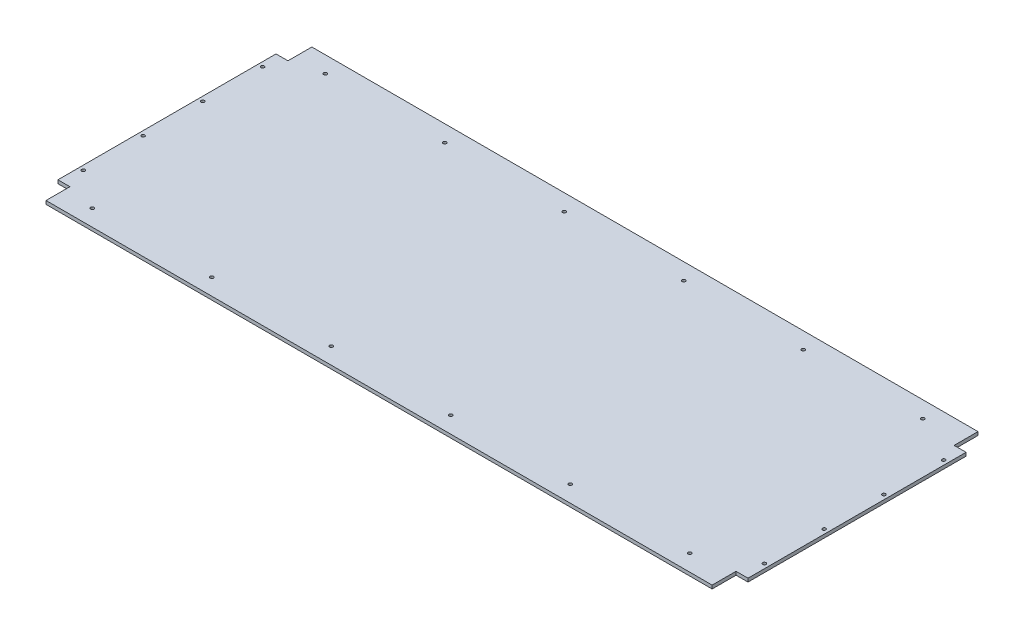
from build123d import *

# Parameters (mm, degrees)
SKETCH1_W           = 1155
SKETCH1_H           = 445
BOSS_EXTRUDE1_DEPTH = 5.715
SKETCH2_W           = 20
SKETCH2_H           = 40
CUT_EXTRUDE1_DEPTH  = 6.715
SKETCH3_R           = 2.75
CUT_EXTRUDE2_DEPTH  = 6.715


with BuildPart() as part:
    # Sketch1 → Boss-Extrude1 (new body)
    with BuildSketch(Plane(origin=(0, 0, 0), x_dir=(1, 0, 0), z_dir=(0, 1, 0))):
        Rectangle(SKETCH1_W, SKETCH1_H)
    extrude(amount=BOSS_EXTRUDE1_DEPTH)

    # Sketch2 → Cut-Extrude1 (cut, through all)
    with BuildSketch(Plane(origin=(0, 5.715, 0), x_dir=(1, 0, 0), z_dir=(0, 1, 0))):
        with Locations((-567.5, 202.5)):
            Rectangle(SKETCH2_W, SKETCH2_H)
        with Locations((-567.5, -202.5)):
            Rectangle(SKETCH2_W, SKETCH2_H)
        with Locations((567.5, -202.5)):
            Rectangle(SKETCH2_W, SKETCH2_H)
        with Locations((567.5, 202.5)):
            Rectangle(SKETCH2_W, SKETCH2_H)
    extrude(amount=-CUT_EXTRUDE1_DEPTH, mode=Mode.SUBTRACT)

    # Sketch3 → Cut-Extrude2 (cut, through all)
    with BuildSketch(Plane(origin=(0, 5.715, 0), x_dir=(1, 0, 0), z_dir=(0, 1, 0))):
        with Locations((-507.5, 195)):
            Circle(SKETCH3_R)
        with Locations((-570, 152.5)):
            Circle(SKETCH3_R)
        with Locations((-307.5, 195)):
            Circle(SKETCH3_R)
        with Locations((-107.5, 195)):
            Circle(SKETCH3_R)
        with Locations((92.5, 195)):
            Circle(SKETCH3_R)
        with Locations((292.5, 195)):
            Circle(SKETCH3_R)
        with Locations((492.5, 195)):
            Circle(SKETCH3_R)
        with Locations((-570, 52.5)):
            Circle(SKETCH3_R)
        with Locations((-570, -47.5)):
            Circle(SKETCH3_R)
        with Locations((-570, -147.5)):
            Circle(SKETCH3_R)
        with Locations((492.5, -195)):
            Circle(SKETCH3_R)
        with Locations((292.5, -195)):
            Circle(SKETCH3_R)
        with Locations((92.5, -195)):
            Circle(SKETCH3_R)
        with Locations((-107.5, -195)):
            Circle(SKETCH3_R)
        with Locations((-307.5, -195)):
            Circle(SKETCH3_R)
        with Locations((-507.5, -195)):
            Circle(SKETCH3_R)
        with Locations((570, -147.5)):
            Circle(SKETCH3_R)
        with Locations((570, -47.5)):
            Circle(SKETCH3_R)
        with Locations((570, 52.5)):
            Circle(SKETCH3_R)
        with Locations((570, 152.5)):
            Circle(SKETCH3_R)
    extrude(amount=-CUT_EXTRUDE2_DEPTH, mode=Mode.SUBTRACT)


solid = part.part
